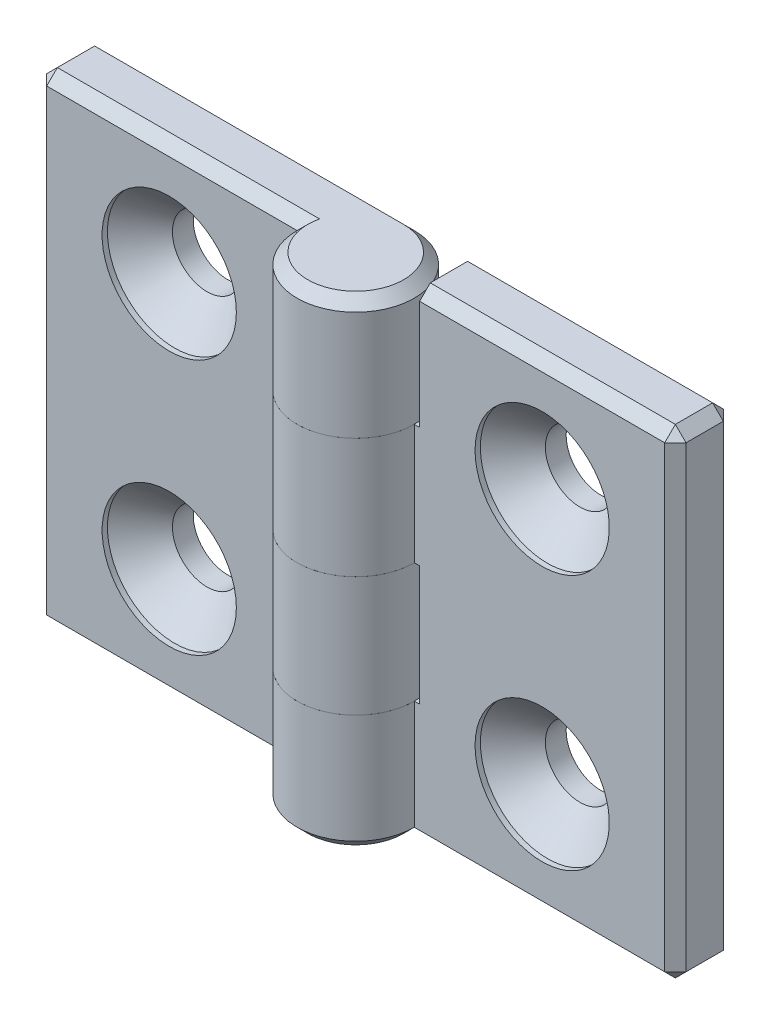
from build123d import *

# Parameters (mm, degrees)
EXTRUDE_1_DEPTH            = 22.5
SKETCH_3_W                 = 11.5
SKETCH_3_H                 = 11.25
CUT_EXTRUDE_1_DEPTH        = 6.5
CUT_EXTRUDE_1_DEPTH_BACK   = 6.5
HOLE_WIZARD_M61_AT_2_COUNT = 2
HOLE_WIZARD_M61_AT_2_PITCH = 24
CHAMFER_1_SIZE             = 1
PATTERN_CIRCULAR_1_COUNT   = 2


with BuildPart() as part:
    # Эскиз1 → Бобышка-Вытянуть1 (new body, symmetric)
    with BuildSketch(Plane(origin=(0, 0, 0), x_dir=(1, 0, 0), z_dir=(0, 1, 0))):
        with BuildLine():
            Line((0, 5.5), (-30, 5.5))
            Line((-30, 5.5), (-30, 0))
            Line((-30, 0), (-5.5, 0))
            ThreePointArc((-5.5, 0), (3.889087297, -3.889087297), (0, 5.5))
        make_face()
    extrude(amount=EXTRUDE_1_DEPTH, both=True)

    # Эскиз3 → Вырез-Вытянуть1 (cut, two sides)
    with BuildSketch(Plane.XY) as cut_extrude_1_sk:
        with Locations((-0.25, 5.625)):
            Rectangle(SKETCH_3_W, SKETCH_3_H)
        with Locations((-0.25, -16.875)):
            Rectangle(SKETCH_3_W, SKETCH_3_H)
    extrude(amount=CUT_EXTRUDE_1_DEPTH, mode=Mode.SUBTRACT)
    extrude(cut_extrude_1_sk.sketch, amount=-CUT_EXTRUDE_1_DEPTH_BACK, mode=Mode.SUBTRACT)

    # Эскиз6 → Зенковка для винта с полупотайной головкой M61 (revolve, cut)
    with BuildSketch(Plane(origin=(-17.5, 12, 0), x_dir=(0, -1, 0), z_dir=(1, 0, 0))):
        Polygon((0, 0), (0, 5.5), (3.25, 5.5), (3.25, 3.55), (6.3, 0.5), (6.3, 0), align=None)
    hole_wizard_m61 = revolve(axis=Axis((-17.5, 12, 6.35), (0, 0, -1)), mode=Mode.SUBTRACT)

    # Зенковка для винта с полупотайной головкой M61 at 2: Зенковка для винта с полупотайной головкой M61 ×2
    with Locations(*[(0, -i * HOLE_WIZARD_M61_AT_2_PITCH, 0) for i in range(1, HOLE_WIZARD_M61_AT_2_COUNT)]):
        add(hole_wizard_m61, mode=Mode.SUBTRACT)

    # Фаска1
    chamfer_1_edges = [part.edges().sort_by_distance(p)[0] for p in [
        (-30, 22.5, -2.75),
        (-18, -22.5, -5.5),
        (-17.75, 22.5, 0),
        (3.889087297, 22.5, 3.889087297),
        (-18, -22.5, 0),
        (-30, -22.5, -2.75),
        (-30, 0, 0),
        (-30, 0, -5.5),
        (-15, 22.5, -5.5),
    ]]
    chamfer(chamfer_1_edges, length=CHAMFER_1_SIZE)


with BuildPart() as pattern_circular_1_1:
    # Круговой массив1: pattern copy
    add(part.part.rotate(Axis((0, 0, 0), (0, 0, 1)), 1 * 360 / PATTERN_CIRCULAR_1_COUNT))


solid = Compound([part.part, pattern_circular_1_1.part])
